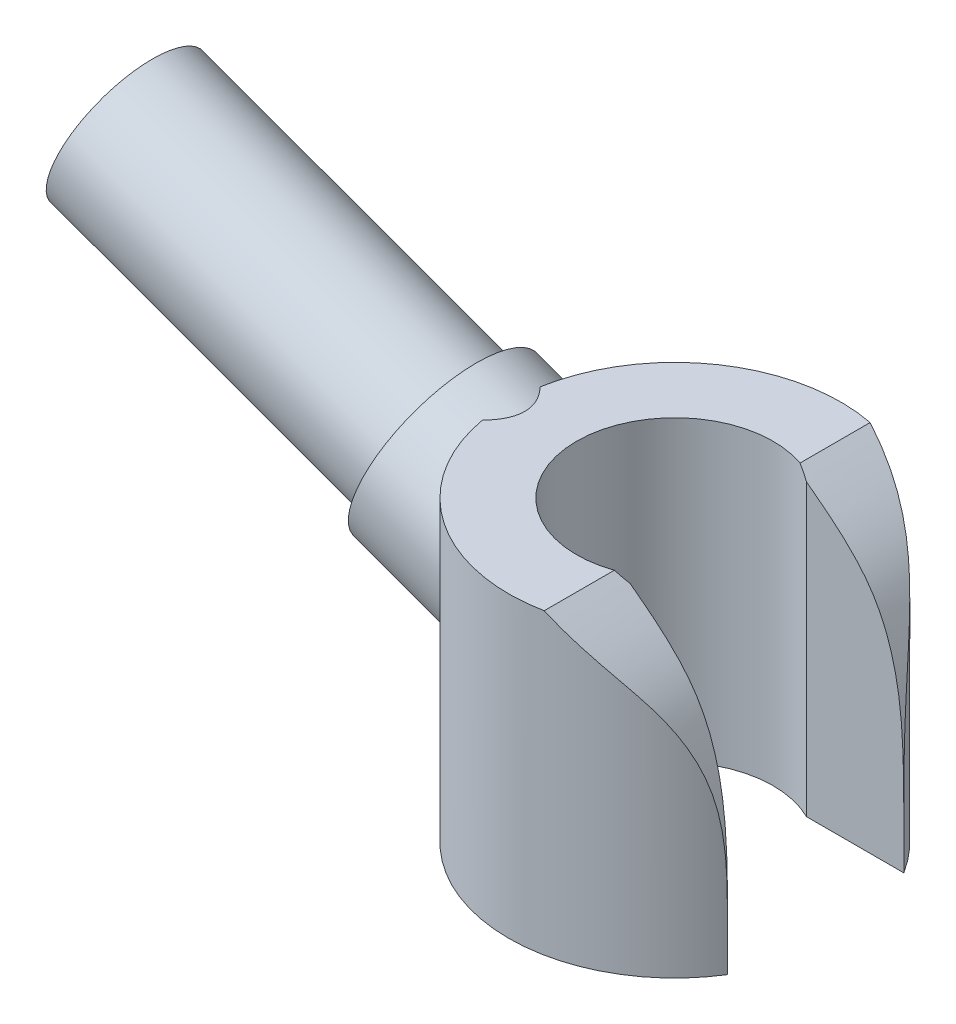
from build123d import *

# Parameters (mm, degrees)
EXTRUDE1_DEPTH             = 4.4
EXTRUDE5_DEPTH             = 6.600446411
EXTRUDE5_DEPTH_BACK        = 6.600446411
EXTRUDE6_REACH             = 8.622
SKETCH15_R                 = 1.35
EXTRUDE6_DIRECTION_2_DEPTH = 1
SKETCH16_R                 = 1.12
EXTRUDE7_DEPTH             = 5


with BuildPart() as part:
    # Sketch1 → Extrude1 (new body)
    with BuildSketch(Plane(origin=(0, 0, 0), x_dir=(1, 0, 0), z_dir=(0, 1, 0))):
        with BuildLine():
            Line((2.076655966, -1.3), (0.642261629, -1.3))
            ThreePointArc((0.642261629, -1.3), (-1.45, 0), (0.642261629, 1.3))
            Line((0.642261629, 1.3), (2.076655966, 1.3))
            ThreePointArc((2.076655966, 1.3), (-2.45, 0), (2.076655966, -1.3))
        make_face()
    extrude(amount=EXTRUDE1_DEPTH)

    # Sketch11 → Extrude5 (cut, two sides: drawn at the far end of the back side and taken through both)
    with BuildSketch(Plane.XY.offset(-EXTRUDE5_DEPTH_BACK)):
        with BuildLine():
            Line((0.476655966, 4.4), (2.076655966, 4.4))
            Line((2.076655966, 4.4), (2.076655966, 0.7))
            add(Edge.make_bspline(
                [(2.076655966, 0.7), (2.075619632, 1.692222339), (2.074022236, 3.22162422), (0.891869454, 4.093697352), (0.476655966, 4.4)],
                knots=[0, 0, 0, 0, 0.648764953, 1, 1, 1, 1], degree=3))
        make_face()
    extrude(amount=EXTRUDE5_DEPTH + EXTRUDE5_DEPTH_BACK, mode=Mode.SUBTRACT)

    # Sketch15 → Extrude6 (add, up to next)
    with BuildSketch(Plane(origin=(-3.143655548, 1.144197046, 0), x_dir=(0, 0, -1), z_dir=(0.9396926207859126, -0.34202014332565683, 0)), mode=Mode.PRIVATE) as extrude6_sk1:
        with Locations((0, 2.028113142)):
            Circle(SKETCH15_R)
    extrude6_tool1 = extrude(extrude6_sk1.sketch, amount=EXTRUDE6_REACH, mode=Mode.PRIVATE) - part.part
    add(extrude6_tool1.solids().sort_by_distance((-2.45, 3.05, 0))[0])

    # Sketch15 → Extrude6 direction 2 (add)
    with BuildSketch(Plane(origin=(-3.143655548, 1.144197046, 0), x_dir=(0, 0, -1), z_dir=(0.9396926207859126, -0.34202014332565683, 0))):
        with Locations((0, 2.028113142)):
            Circle(SKETCH15_R)
    extrude(amount=-EXTRUDE6_DIRECTION_2_DEPTH)

    # Sketch16 → Extrude7 (add)
    with BuildSketch(Plane(origin=(-4.083348168, 1.486217189, 0), x_dir=(0, 0, 1), z_dir=(-0.9396926207859126, 0.34202014332565694, 0))):
        with Locations((0, 2.028113142)):
            Circle(SKETCH16_R)
    extrude(amount=EXTRUDE7_DEPTH)


solid = part.part
